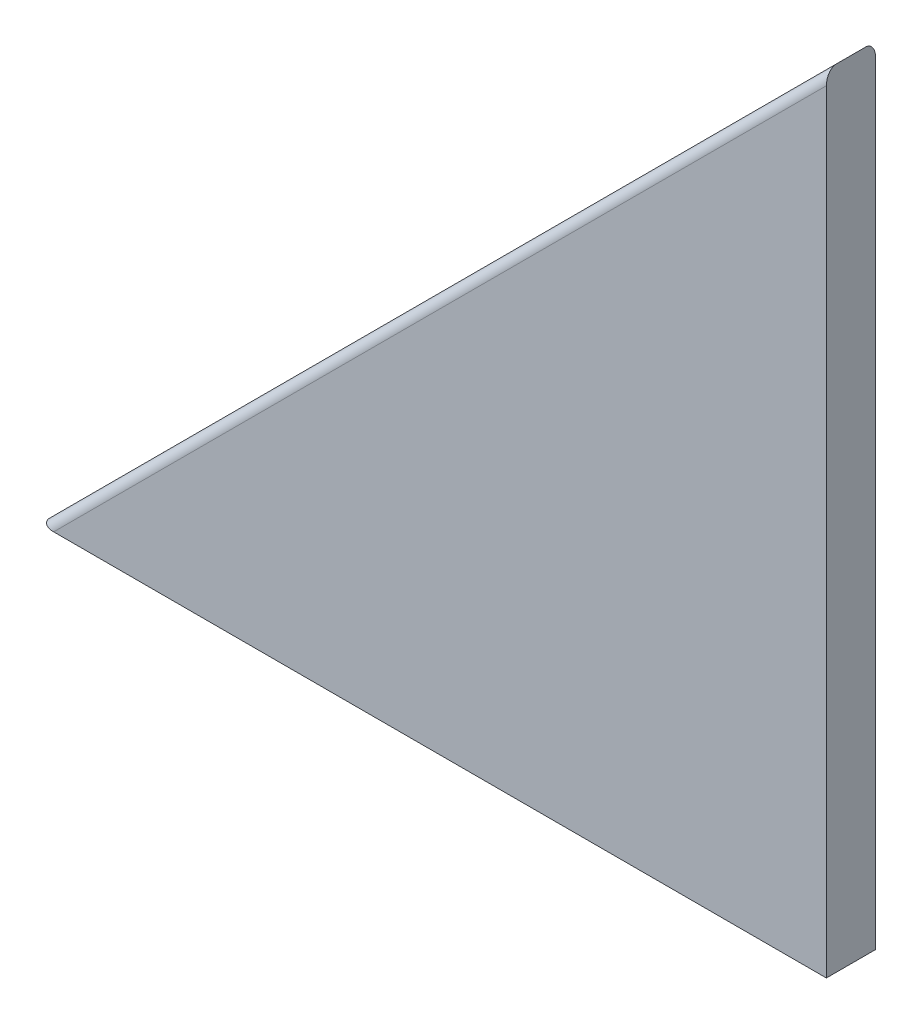
from build123d import *

# Parameters (mm, degrees)
BOSS_EXTRUDE1_DEPTH = 6.35
FILLET2_R           = 1.27
FILLET3_R           = 1.27


with BuildPart() as part:
    # Sketch1 → Boss-Extrude1 (new body)
    with BuildSketch(Plane.XY):
        Polygon((0, 0), (-101.6, 0), (0, 101.6), align=None)
    extrude(amount=BOSS_EXTRUDE1_DEPTH)

    # Fillet2
    fillet2_edges = [part.edges().sort_by_distance(p)[0] for p in [
        (-50.8, 50.8, 6.35),
    ]]
    fillet(fillet2_edges, radius=FILLET2_R)

    # Fillet3
    fillet3_edges = [part.edges().sort_by_distance(p)[0] for p in [
        (-50.8, 50.8, 0),
    ]]
    fillet(fillet3_edges, radius=FILLET3_R)


solid = part.part
